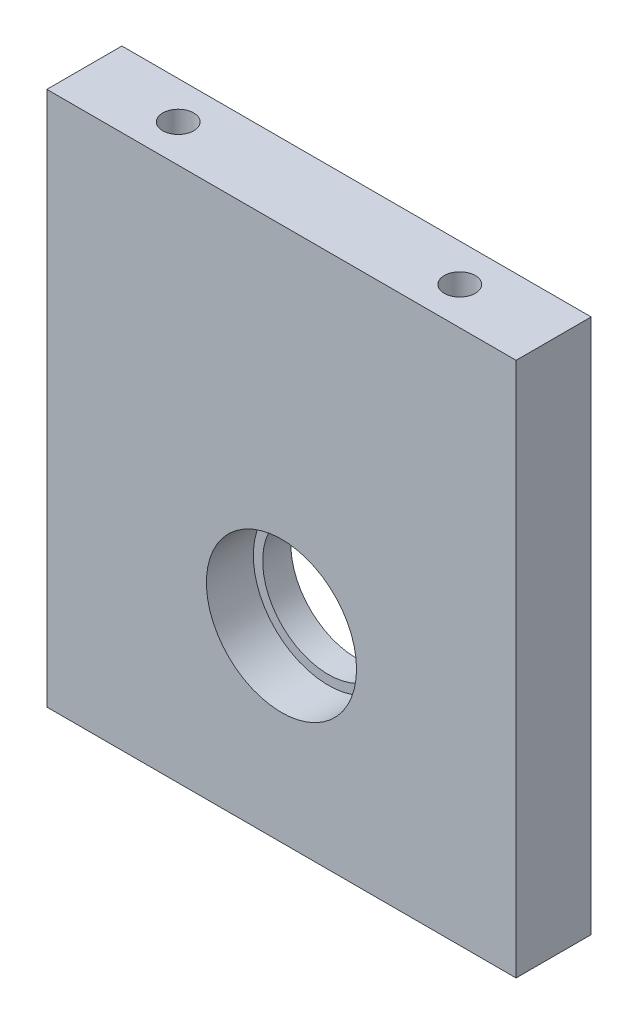
from build123d import *

# Parameters (mm, degrees)
ESQUISSE1_W             = 50
ESQUISSE1_H             = 57
ESQUISSE1_R             = 7
BOSS_EXTRU_1_DEPTH      = 8
ESQUISSE2_R             = 8
ENL_V_MAT_EXTRU_1_DEPTH = 5
ESQUISSE3_R             = 1.65
ENL_V_MAT_EXTRU_2_DEPTH = 10


with BuildPart() as part:
    # Esquisse1 → Boss.-Extru.1 (new body)
    with BuildSketch(Plane.XY):
        with Locations((25, 28.5)):
            Rectangle(ESQUISSE1_W, ESQUISSE1_H)
        with Locations((25, 20)):
            Circle(ESQUISSE1_R, mode=Mode.SUBTRACT)
    extrude(amount=BOSS_EXTRU_1_DEPTH)

    # Esquisse2 → Enlèv. mat.-Extru.1 (cut)
    with BuildSketch(Plane.XY.offset(8)):
        with Locations((25, 20)):
            Circle(ESQUISSE2_R)
    extrude(amount=-ENL_V_MAT_EXTRU_1_DEPTH, mode=Mode.SUBTRACT)

    # Esquisse3 → Enlèv. mat.-Extru.2 (cut)
    with BuildSketch(Plane(origin=(0, 57, 0), x_dir=(1, 0, 0), z_dir=(0, 1, 0))):
        with Locations((10, -4)):
            Circle(ESQUISSE3_R)
        with Locations((40, -4)):
            Circle(ESQUISSE3_R)
    extrude(amount=-ENL_V_MAT_EXTRU_2_DEPTH, mode=Mode.SUBTRACT)


solid = part.part
